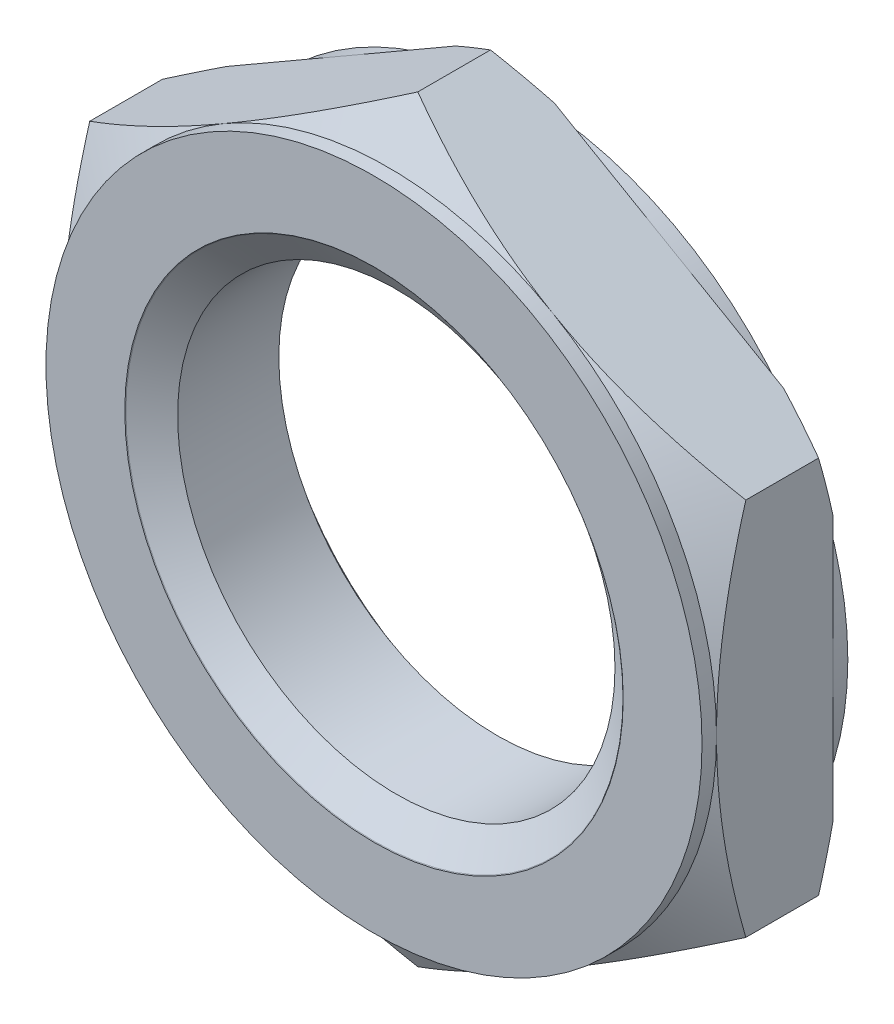
from build123d import *

# Parameters (mm, degrees)
BASENUTSKE_R       = 5.25
BASENUT_DEPTH      = 4
SKETCH4_W          = 0.4064
SKETCH4_H          = 11.392304845
SKETCH6_R          = 6
CUT_EXTRUDE1_DEPTH = 10


with BuildPart() as part:
    # BaseNutSke → BaseNut (new body)
    with BuildSketch(Plane.XY):
        Polygon((9, 5.196152423), (9, -5.196152423), (0, -10.392304845), (-9, -5.196152423), (-9, 5.196152423), (0, 10.392304845), align=None)
        Circle(BASENUTSKE_R, mode=Mode.SUBTRACT)
    extrude(amount=-BASENUT_DEPTH)

    # Sketch4 → Bearing-Face (revolve, cut)
    with BuildSketch(Plane(origin=(0, 0, 0), x_dir=(0, 0, -1), z_dir=(1, 0, 0))):
        with Locations((3.7968, 14.696152423)):
            Rectangle(SKETCH4_W, SKETCH4_H)
        Polygon((0, 9), (-10, 9), (-10, 20.392304845), (0.803847577, 20.392304845), (0.803847577, 10.392304845), align=None)
    revolve(axis=Axis((0, 0, 0), (0, 0, -1)), mode=Mode.SUBTRACT)

    # Sketch3 → Double-Chamfer (revolve, cut)
    with BuildSketch(Plane(origin=(0, 0, 0), x_dir=(0, 0, -1), z_dir=(1, 0, 0))):
        Polygon((4, 9), (3.196152423, 10.392304845), (3.196152423, 20.392304845), (14, 20.392304845), (14, 9), align=None)
        Polygon((1.201295155, 20.392304845), (-9.602552423, 20.392304845), (-9.602552423, 9), (0.397447577, 9), (1.201295155, 10.392304845), align=None)
    revolve(axis=Axis((0, 0, 0), (0, 0, -1)), mode=Mode.SUBTRACT)

    # Sketch5 → EndChamfer (revolve, cut)
    with BuildSketch(Plane(origin=(0, 0, 0), x_dir=(0, 0, -1), z_dir=(1, 0, 0))):
        Polygon((3.9746, 6.8375), (2.751862586, 5.09125), (4.0254, 5.09125), (4.0254, 6.8375), align=None)
        Polygon((-0.0508, 6.8375), (0, 6.8375), (1.222737414, 5.09125), (-0.0508, 5.09125), align=None)
    revolve(axis=Axis((0, 0, -25.037505729), (0, 0, -1)), mode=Mode.SUBTRACT)

    # ThdSchSke → ThreadSchematic (revolve, cut)
    with BuildSketch(Plane(origin=(0, 0, 0), x_dir=(1, 0, 0), z_dir=(0, 1, 0))):
        Polygon((-6.8375, 0.0254), (-5.25, 1.136979467), (-2.625, 1.136979467), (-2.625, -1.086179467), (-5.25, -1.086179467), align=None)
    revolve(axis=Axis((0, 0, -3.175), (0, 0, 1)), mode=Mode.SUBTRACT)

    # Sketch6 → Cut-Extrude1 (cut)
    with BuildSketch(Plane.XY):
        Circle(SKETCH6_R)
    extrude(amount=-CUT_EXTRUDE1_DEPTH, mode=Mode.SUBTRACT)


solid = part.part
